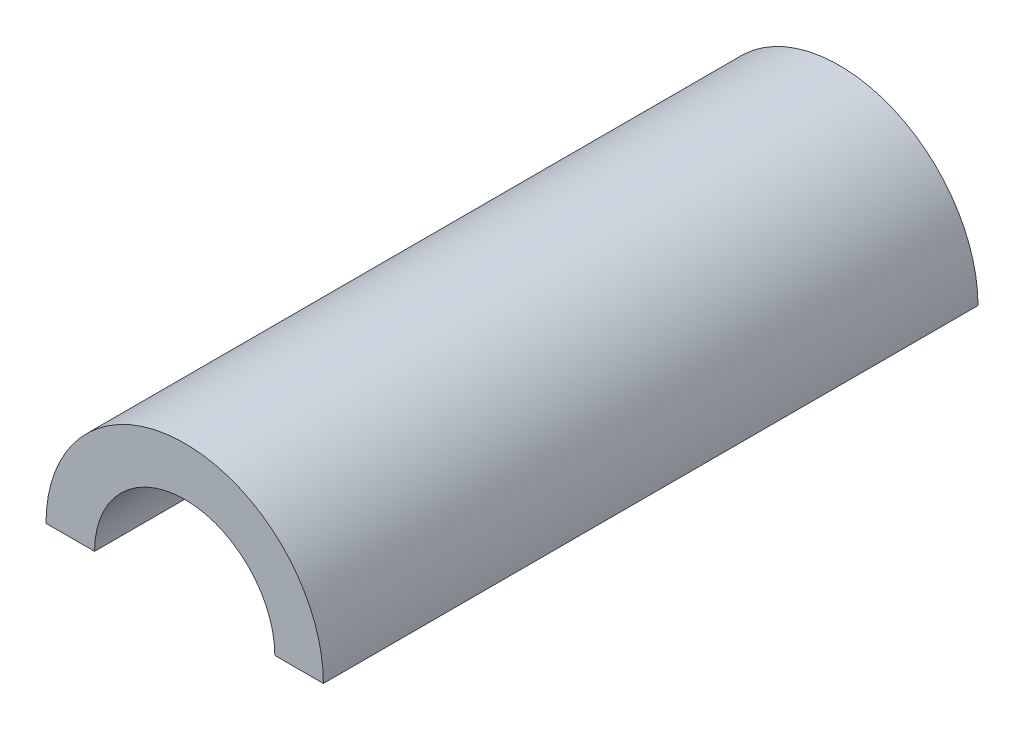
from build123d import *

# Parameters (mm, degrees)
BOSS_EXTRUDE1_DEPTH = 47.2


with BuildPart() as part:
    # Sketch2 → Boss-Extrude1 (new body)
    with BuildSketch(Plane.XY):
        with BuildLine():
            Line((6.5, 0), (10, 0))
            ThreePointArc((10, 0), (0, 10), (-10, 0))
            Line((-10, 0), (-6.5, 0))
            ThreePointArc((-6.5, 0), (0, 6.5), (6.5, 0))
        make_face()
    extrude(amount=BOSS_EXTRUDE1_DEPTH)


solid = part.part
